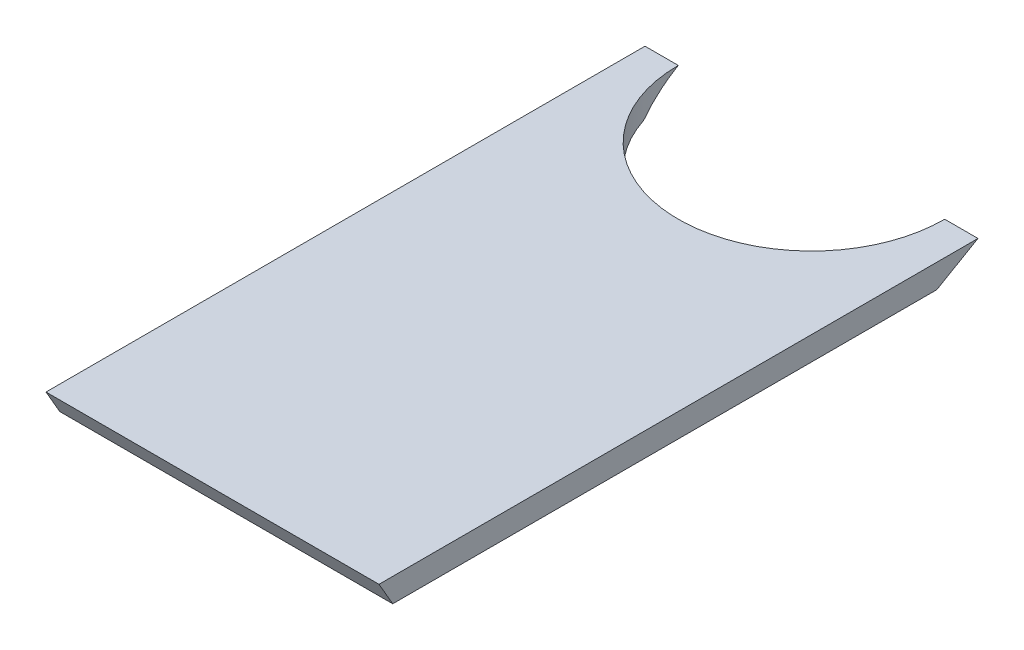
from build123d import *

# Parameters (mm, degrees)
BOSS_EXTRUDE1_DEPTH = 44.45
CUT_EXTRUDE1_DEPTH  = 7.35


with BuildPart() as part:
    # Sketch3 → Boss-Extrude1 (new body, symmetric)
    with BuildSketch(Plane(origin=(0, 0, 0), x_dir=(0, 0, -1), z_dir=(1, 0, 0))):
        Polygon((-88.825470595, 3.175), (-85.159296386, -3.175), (60.083377372, -3.175), (71.0819, 3.175), align=None)
    extrude(amount=BOSS_EXTRUDE1_DEPTH, both=True)

    # Sketch5 → Cut-Extrude1 (cut, through all)
    with BuildSketch(Plane(origin=(0, 3.175, 0), x_dir=(1, 0, 0), z_dir=(0, 1, 0))):
        with BuildLine():
            ThreePointArc((-35.56, 71.0819), (0, 35.5219), (35.56, 71.0819))
            Line((35.56, 71.0819), (-35.56, 71.0819))
        make_face()
    extrude(amount=-CUT_EXTRUDE1_DEPTH, mode=Mode.SUBTRACT)


solid = part.part
